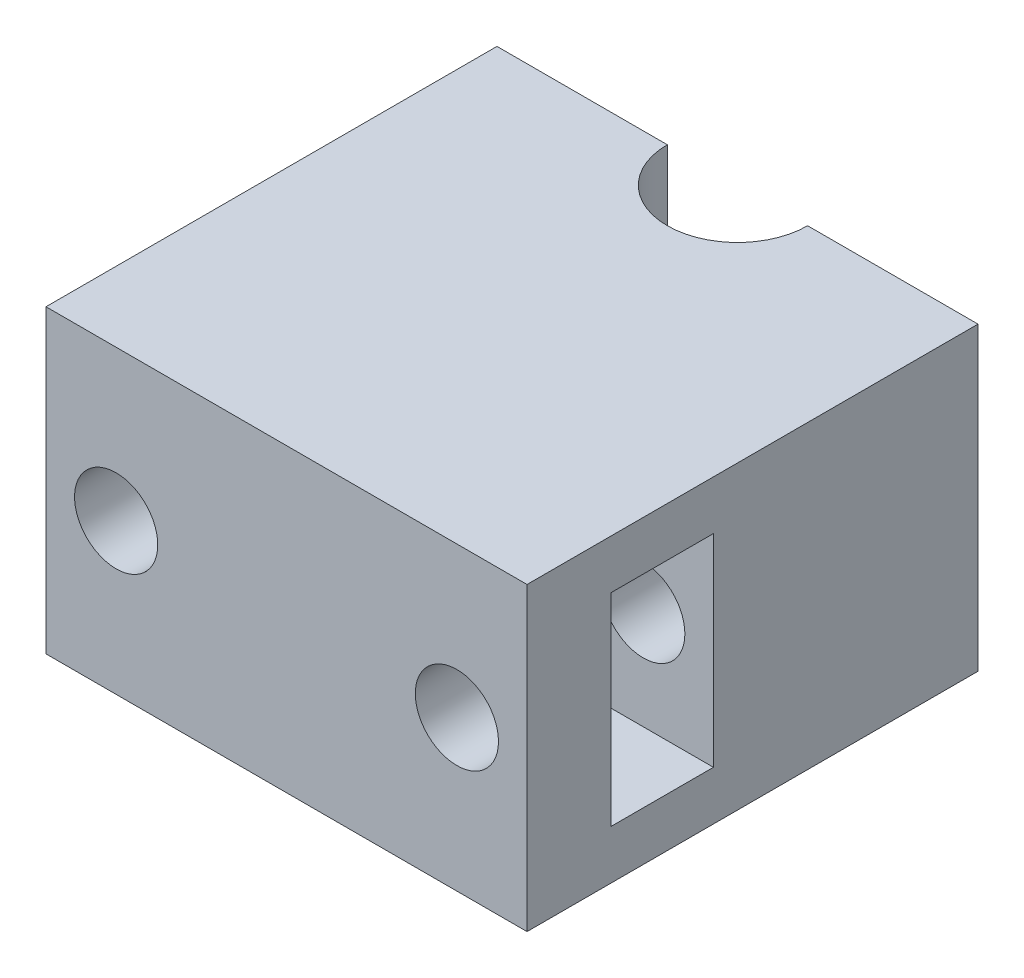
from build123d import *

# Parameters (mm, degrees)
SKETCH1_W               = 48
SKETCH1_H               = 45
BOSS_EXTRUDE1_DEPTH     = 30
SKETCH2_W               = 10.2
SKETCH2_H               = 20.2
CUT_EXTRUDE1_DEPTH      = 45
SKETCH3_R               = 4.15
CUT_EXTRUDE2_DEPTH      = 46
CUT_EXTRUDE3_DEPTH      = 1
CUT_EXTRUDE3_DEPTH_BACK = 31


with BuildPart() as part:
    # Sketch1 → Boss-Extrude1 (new body)
    with BuildSketch(Plane(origin=(0, 0, 0), x_dir=(1, 0, 0), z_dir=(0, 1, 0))):
        Rectangle(SKETCH1_W, SKETCH1_H)
    extrude(amount=BOSS_EXTRUDE1_DEPTH)

    # Sketch2 → Cut-Extrude1 (cut)
    with BuildSketch(Plane(origin=(24, 0, 0), x_dir=(0, 0, -1), z_dir=(1, 0, 0))):
        with Locations((-9, 15)):
            Rectangle(SKETCH2_W, SKETCH2_H)
    extrude(amount=-CUT_EXTRUDE1_DEPTH, mode=Mode.SUBTRACT)

    # Sketch3 → Cut-Extrude2 (cut, through all)
    with BuildSketch(Plane.XY.offset(22.5)):
        with Locations((-17, 15)):
            Circle(SKETCH3_R)
        with Locations((17, 15)):
            Circle(SKETCH3_R)
    extrude(amount=-CUT_EXTRUDE2_DEPTH, mode=Mode.SUBTRACT)

    # Sketch4 → Cut-Extrude3 (cut, two sides)
    with BuildSketch(Plane(origin=(0, 30, 0), x_dir=(1, 0, 0), z_dir=(0, 1, 0))) as cut_extrude3_sk:
        with BuildLine():
            Line((-7, 141.788608739), (-7, 22.5))
            ThreePointArc((-7, 22.5), (0, 15.5), (7, 22.5))
            Line((7, 22.5), (7, 141.788608739))
            Line((7, 141.788608739), (7, 380.365826216))
            Line((7, 380.365826216), (-7, 380.365826216))
            Line((-7, 380.365826216), (-7, 141.788608739))
        make_face()
    extrude(amount=CUT_EXTRUDE3_DEPTH, mode=Mode.SUBTRACT)
    extrude(cut_extrude3_sk.sketch, amount=-CUT_EXTRUDE3_DEPTH_BACK, mode=Mode.SUBTRACT)


solid = part.part
